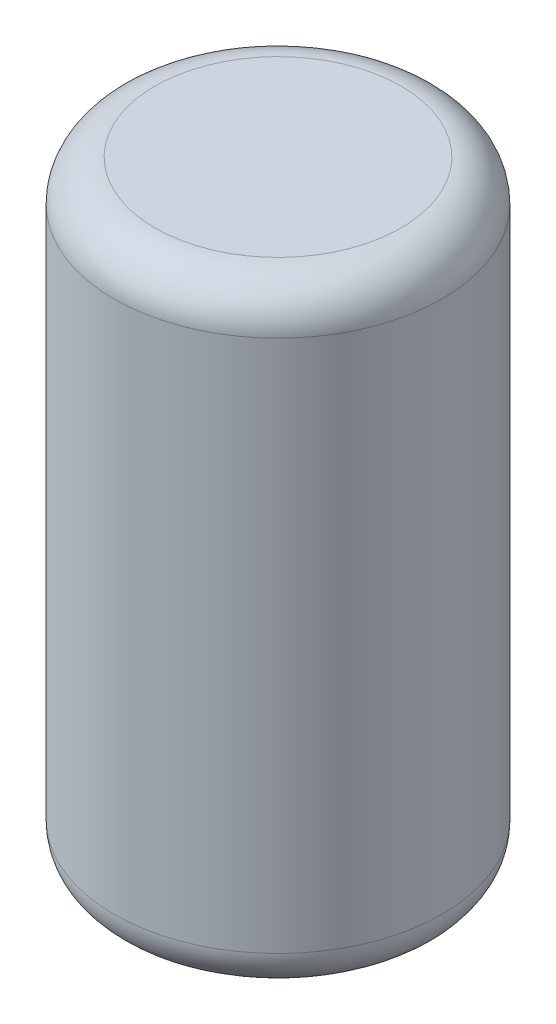
from build123d import *

# Parameters (mm, degrees)
SKETCH1_R           = 4
BOSS_EXTRUDE1_DEPTH = 15
FILLET1_R           = 1


with BuildPart() as part:
    # Sketch1 → Boss-Extrude1 (new body)
    with BuildSketch(Plane(origin=(0, 0, 0), x_dir=(1, 0, 0), z_dir=(0, 1, 0))):
        Circle(SKETCH1_R)
    extrude(amount=BOSS_EXTRUDE1_DEPTH)

    # Fillet1
    fillet1_edges = [part.edges().sort_by_distance(p)[0] for p in [
        (-4, 0, 0),
        (-4, 15, 0),
    ]]
    fillet(fillet1_edges, radius=FILLET1_R)


solid = part.part
